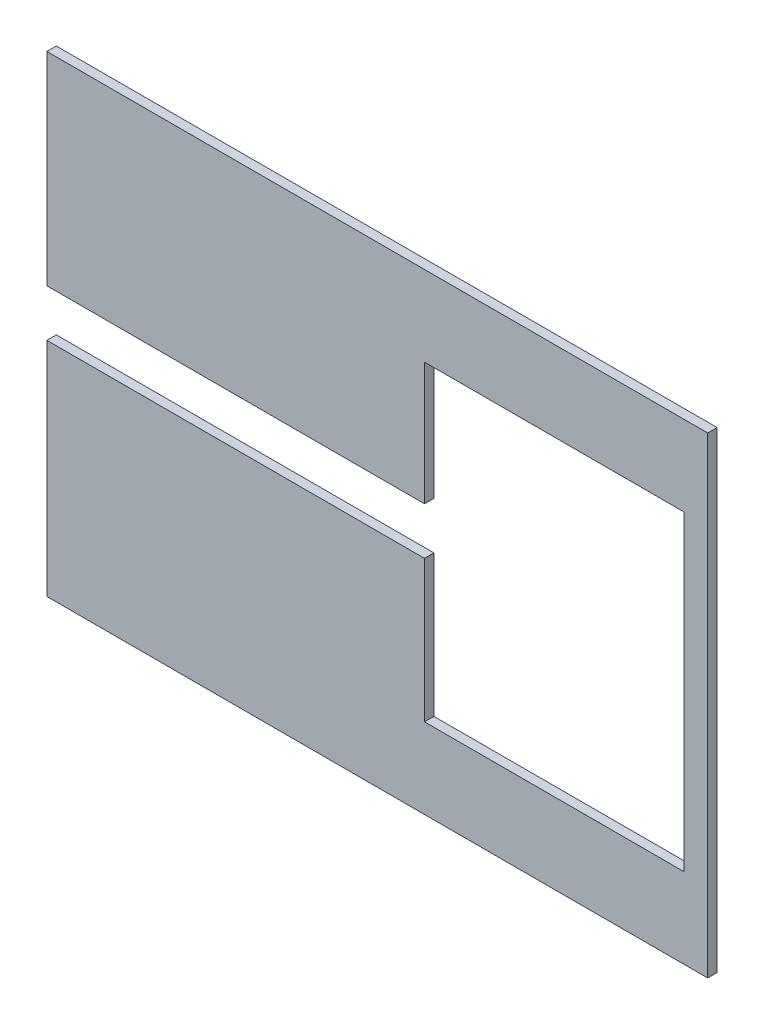
from build123d import *

# Parameters (mm, degrees)
ESQUISSE1_W             = 140
ESQUISSE1_H             = 100
BOSS_EXTRU_1_DEPTH      = 2
ESQUISSE2_W             = 55
ESQUISSE2_H             = 66
ENL_V_MAT_EXTRU_1_DEPTH = 2
ESQUISSE3_W             = 78
ESQUISSE3_H             = 10
ESQUISSE3_W_2           = 2
ENL_V_MAT_EXTRU_2_DEPTH = 3


with BuildPart() as part:
    # Esquisse1 → Boss.-Extru.1 (new body)
    with BuildSketch(Plane.XY):
        with Locations((70, 50)):
            Rectangle(ESQUISSE1_W, ESQUISSE1_H)
    extrude(amount=BOSS_EXTRU_1_DEPTH)

    # Esquisse2 → Enlèv. mat.-Extru.1 (cut)
    with BuildSketch(Plane.XY.offset(2)):
        with Locations((107.5, 50)):
            Rectangle(ESQUISSE2_W, ESQUISSE2_H)
    extrude(amount=-ENL_V_MAT_EXTRU_1_DEPTH, mode=Mode.SUBTRACT)

    # Esquisse3 → Enlèv. mat.-Extru.2 (cut)
    with BuildSketch(Plane.XY.offset(2)):
        with Locations((39, 52)):
            Rectangle(ESQUISSE3_W, ESQUISSE3_H)
        with Locations((79, 52)):
            Rectangle(ESQUISSE3_W_2, ESQUISSE3_H)
    extrude(amount=-ENL_V_MAT_EXTRU_2_DEPTH, mode=Mode.SUBTRACT)


solid = part.part
